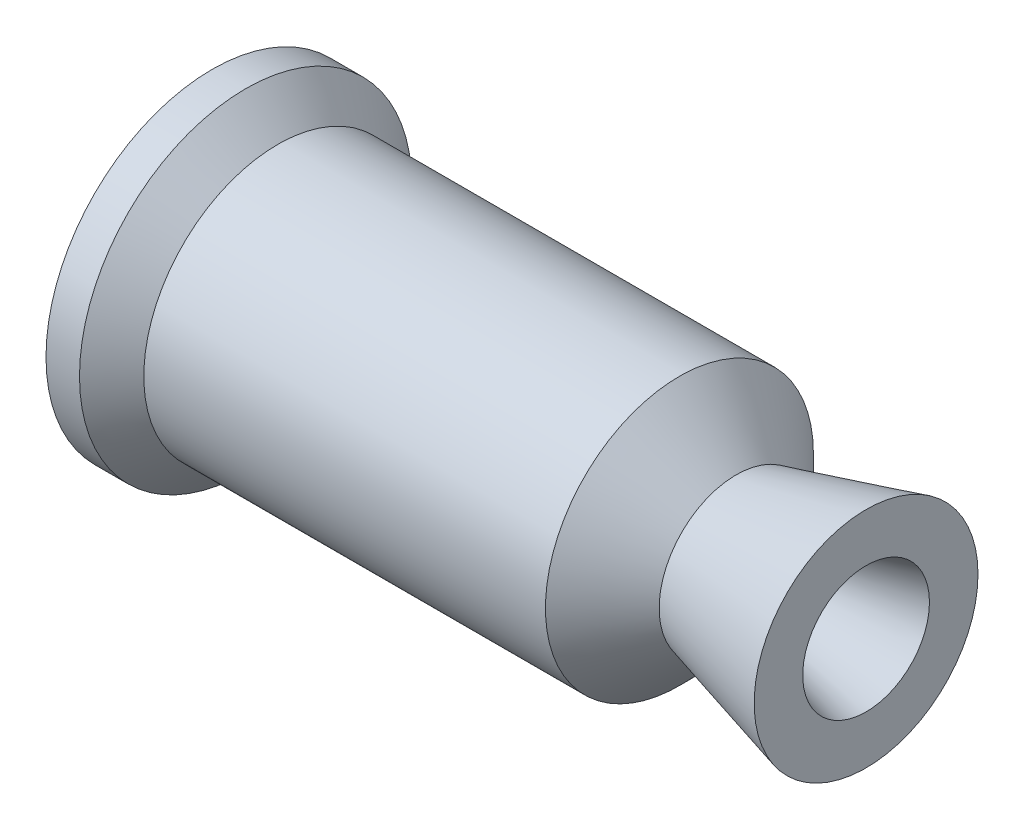
from build123d import *

# Parameters (mm, degrees)
SKETCH1_W          = 6.35
SKETCH1_H          = 6.096
SKETCH2_R          = 29.718
SKETCH2_R_2        = 26.543
CUT_EXTRUDE1_DEPTH = 2.032


with BuildPart() as part:
    # Sketch1 → Revolve1 (revolve)
    with BuildSketch(Plane.XY):
        Polygon((0, 25.4), (0, 18.8722), (82.55, 18.8722), (95.4532, 5.969), (101.4222, 5.969), (123.983193542, 12.0142), (123.983193542, 21.217805244), (99.371450104, 14.623108465), (88.594558569, 25.4), (12.446, 25.4), (6.35, 25.4), align=None)
        with Locations((3.175, 28.448)):
            Rectangle(SKETCH1_W, SKETCH1_H)
        Polygon((6.35, 31.496), (6.35, 25.4), (12.446, 25.4), align=None)
    revolve(axis=Axis((0, 0, 0), (-1, 0, 0)))

    # Sketch2 → Cut-Extrude1 (cut)
    with BuildSketch(Plane.ZY):
        Circle(SKETCH2_R)
        Circle(SKETCH2_R_2, mode=Mode.SUBTRACT)
    extrude(amount=-CUT_EXTRUDE1_DEPTH, mode=Mode.SUBTRACT)


solid = part.part
